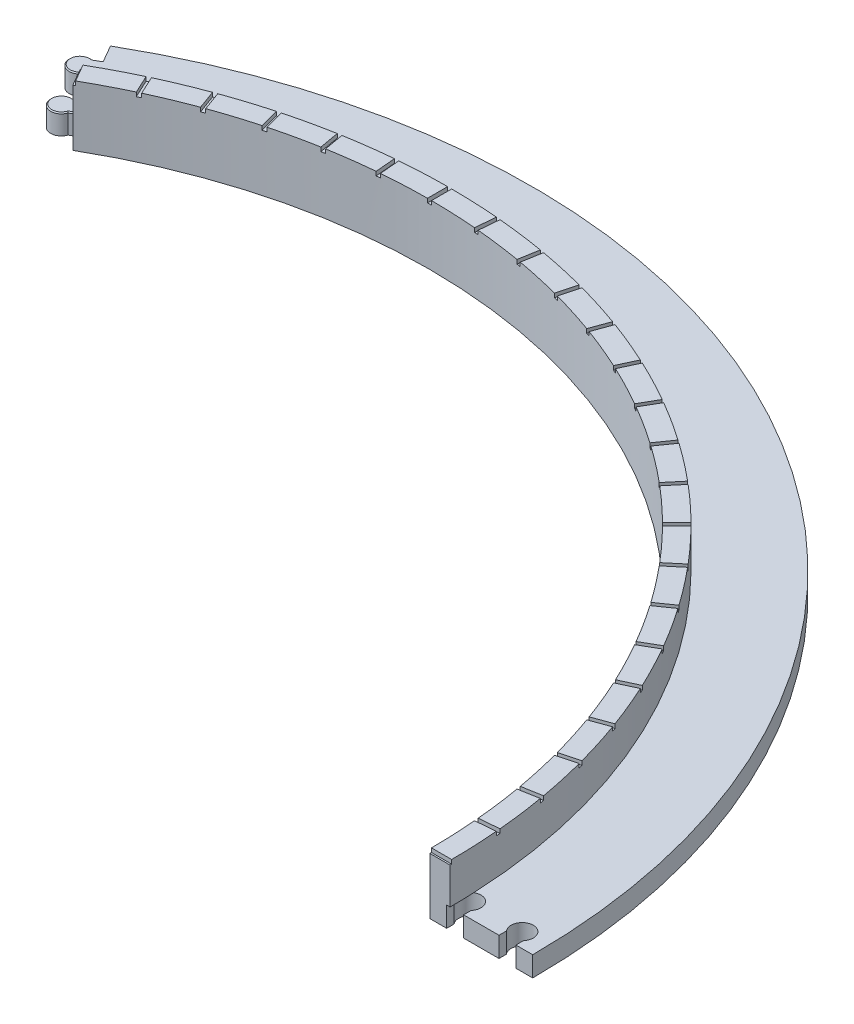
from build123d import *

# Parameters (mm, degrees)
BOSS_EXTRUDE1_DEPTH = 5
BOSS_EXTRUDE2_DEPTH = 10
BOSS_EXTRUDE3_DEPTH = 5
CUT_EXTRUDE1_DEPTH  = 5
CUT_EXTRUDE2_DEPTH  = 1
CIRPATTERN1_COUNT   = 25
CIRPATTERN1_ANGLE   = 120
CUT_EXTRUDE3_DEPTH  = 16
CHAMFER1_SIZE       = 0.25


with BuildPart() as part:
    # Sketch1 → Boss-Extrude1 (new body)
    with BuildSketch(Plane(origin=(0, 0, 0), x_dir=(1, 0, 0), z_dir=(0, 1, 0))):
        with BuildLine():
            Line((-69.75, 120.810543828), (-82.5, 142.894191624))
            ThreePointArc((-82.5, 142.894191624), (82.5, 142.894191624), (165, 0))
            Line((165, 0), (139.5, 0))
            ThreePointArc((139.5, 0), (69.75, 120.810543828), (-69.75, 120.810543828))
        make_face()
    extrude(amount=BOSS_EXTRUDE1_DEPTH)

    # Sketch2 → Boss-Extrude2 (add)
    with BuildSketch(Plane(origin=(0, 5, 0), x_dir=(1, 0, 0), z_dir=(0, 1, 0))):
        with BuildLine():
            Line((-72.25, 125.140670847), (-69.75, 120.810543828))
            ThreePointArc((-69.75, 120.810543828), (69.75, 120.810543828), (139.5, 0))
            Line((139.5, 0), (144.5, 0))
            ThreePointArc((144.5, 0), (72.25, 125.140670847), (-72.25, 125.140670847))
        make_face()
    extrude(amount=BOSS_EXTRUDE2_DEPTH)

    # Sketch3 → Boss-Extrude3 (add)
    with BuildSketch(Plane(origin=(0, 5, 0), x_dir=(1, 0, 0), z_dir=(0, 1, 0))):
        with BuildLine():
            Line((-71.88125, 124.501977112), (-73.88125, 127.966078727))
            Line((-73.88125, 127.966078727), (-75.613300808, 126.966078727))
            ThreePointArc((-75.613300808, 126.966078727), (-78.430339344, 123.030259693), (-73.613300808, 123.501977112))
            Line((-73.613300808, 123.501977112), (-71.88125, 124.501977112))
        make_face()
        with BuildLine():
            Line((-78.14375, 135.348945294), (-80.14375, 138.813046909))
            Line((-80.14375, 138.813046909), (-81.875800808, 137.813046909))
            ThreePointArc((-81.875800808, 137.813046909), (-84.692839344, 133.877227875), (-79.875800808, 134.348945294))
            Line((-79.875800808, 134.348945294), (-78.14375, 135.348945294))
        make_face()
    extrude(amount=-BOSS_EXTRUDE3_DEPTH)

    # Sketch4 → Cut-Extrude1 (cut)
    with BuildSketch(Plane(origin=(0, 0, 0), x_dir=(1, 0, 0), z_dir=(0, 1, 0))):
        with BuildLine():
            Line((156.6375, 1.962821416), (156.6375, 0))
            Line((156.6375, 0), (160.8375, 0))
            Line((160.8375, 0), (160.8375, 1.962821416))
            ThreePointArc((160.8375, 1.962821416), (158.7375, 6.507536453), (156.6375, 1.962821416))
        make_face()
        with BuildLine():
            Line((143.6625, 1.962821416), (143.6625, 0))
            Line((143.6625, 0), (147.8625, 0))
            Line((147.8625, 0), (147.8625, 1.962821416))
            ThreePointArc((147.8625, 1.962821416), (145.7625, 6.507536453), (143.6625, 1.962821416))
        make_face()
    extrude(amount=CUT_EXTRUDE1_DEPTH, mode=Mode.SUBTRACT)

    # Sketch5 → Cut-Extrude2 (cut)
    with BuildSketch(Plane(origin=(0, 15, 0), x_dir=(1, 0, 0), z_dir=(0, 1, 0))):
        Polygon((-72.659271704, 126.849550232), (-68.346968319, 119.380421672), (-69.212993723, 118.880421672), (-73.606467483, 126.490141447), align=None)
    cut_extrude2 = extrude(amount=-CUT_EXTRUDE2_DEPTH, mode=Mode.SUBTRACT)

    # CirPattern1: Cut-Extrude2 ×25 about axis
    cirpattern1_axis = Axis((0, 0, 0), (0, -1, 0))
    for i in range(1, CIRPATTERN1_COUNT):
        add(cut_extrude2.rotate(cirpattern1_axis, i * CIRPATTERN1_ANGLE / (CIRPATTERN1_COUNT - 1)), mode=Mode.SUBTRACT)

    # Sketch6 → Cut-Extrude3 (cut, through all)
    with BuildSketch(Plane(origin=(0, 15, 0), x_dir=(1, 0, 0), z_dir=(0, 1, 0))):
        Polygon((134.134253662, 0), (167.805161023, 0), (167.805161023, 0.1), (133.91215317, 0.1), align=None)
    extrude(amount=-CUT_EXTRUDE3_DEPTH, mode=Mode.SUBTRACT)

    # Chamfer1
    chamfer1_edges = [part.edges().sort_by_distance(p)[0] for p in [
        (-81.009775404, 5, -138.313046909),
        (-84.692839344, 5, -133.877227875),
        (-79.009775404, 5, -134.848945294),
        (-74.747275404, 5, -127.466078727),
        (-78.430339344, 5, -123.030259693),
        (-72.747275404, 5, -124.001977112),
    ]]
    chamfer(chamfer1_edges, length=CHAMFER1_SIZE)


solid = part.part
